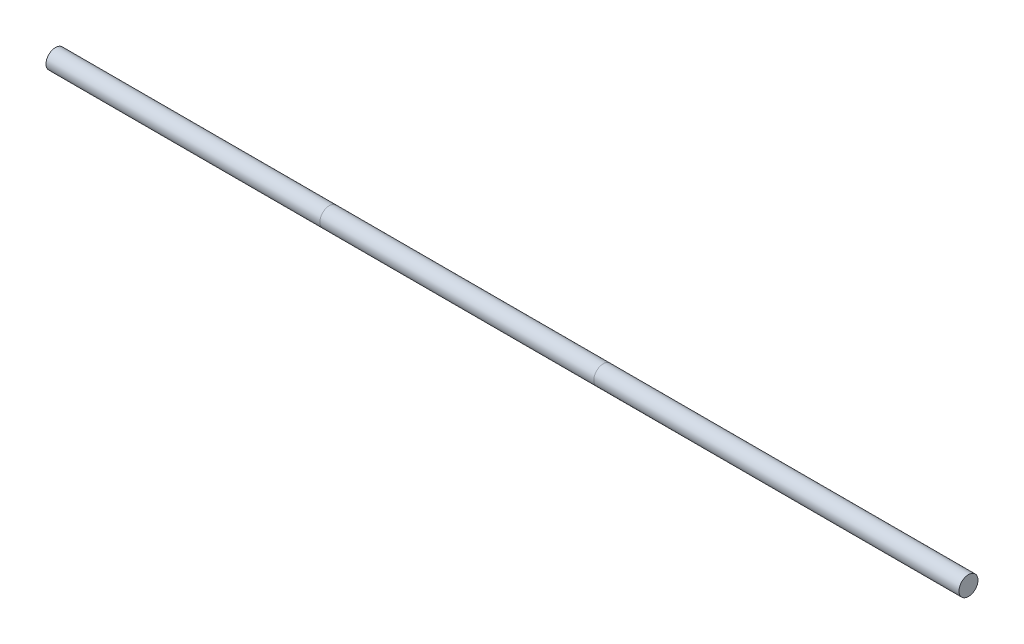
from build123d import *

# Parameters (mm, degrees)
SKETCH2_R           = 31.75
BOSS_EXTRUDE1_DEPTH = 914.4
BOSS_EXTRUDE2_START = 914.4
SKETCH2_2_R         = 31.75
BOSS_EXTRUDE2_DEPTH = 914.4
BOSS_EXTRUDE3_START = 1828.8
SKETCH2_3_R         = 31.75
BOSS_EXTRUDE3_DEPTH = 1219.2


with BuildPart() as part:
    # Sketch2 → Boss-Extrude1 (new body)
    with BuildSketch(Plane(origin=(0, 0, 0), x_dir=(0, 0, -1), z_dir=(1, 0, 0))):
        Circle(SKETCH2_R)
    extrude(amount=BOSS_EXTRUDE1_DEPTH)


with BuildPart() as body_2:
    # Sketch2_2 → Boss-Extrude2 (new body)
    with BuildSketch(Plane(origin=(0, 0, 0), x_dir=(0, 0, -1), z_dir=(1, 0, 0)).offset(BOSS_EXTRUDE2_START)):
        Circle(SKETCH2_2_R)
    extrude(amount=BOSS_EXTRUDE2_DEPTH)


with BuildPart() as body_3:
    # Sketch2_3 → Boss-Extrude3 (new body)
    with BuildSketch(Plane(origin=(0, 0, 0), x_dir=(0, 0, -1), z_dir=(1, 0, 0)).offset(BOSS_EXTRUDE3_START)):
        Circle(SKETCH2_3_R)
    extrude(amount=BOSS_EXTRUDE3_DEPTH)


solid = Compound([part.part, body_2.part, body_3.part])
